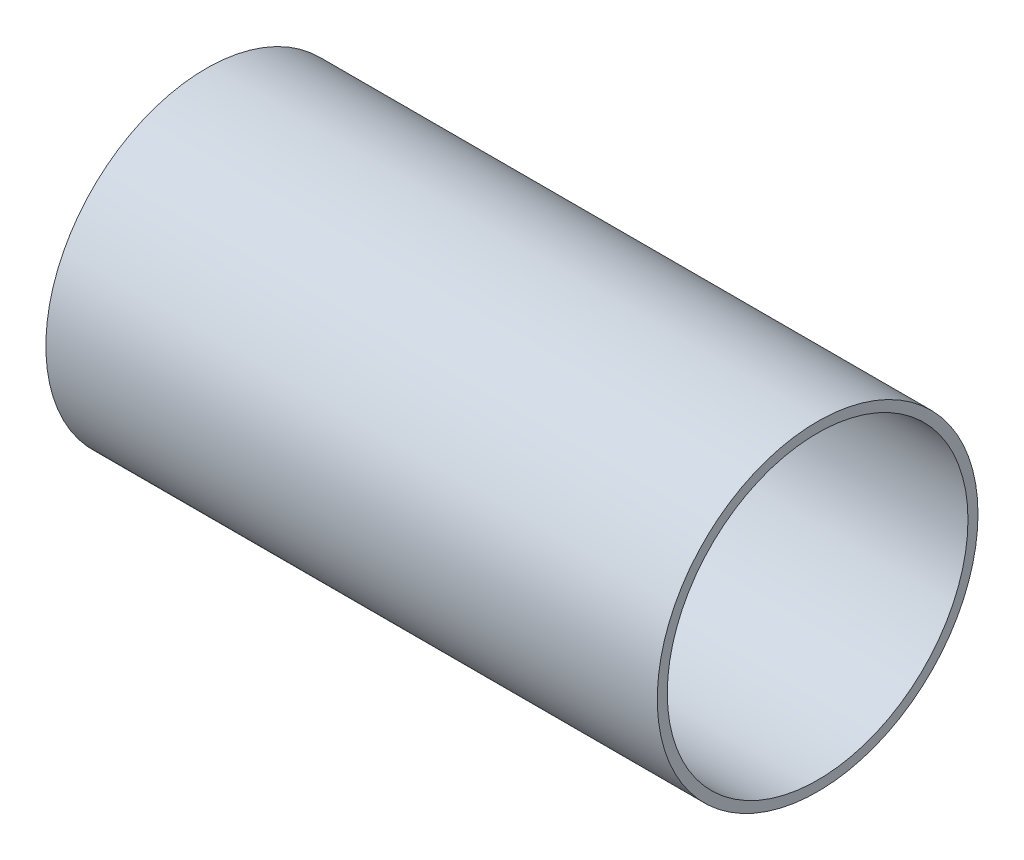
from build123d import *

# Parameters (mm, degrees)
SKETCH1_R           = 101.6
SKETCH1_R_2         = 95.25
BOSS_EXTRUDE1_DEPTH = 387.35


with BuildPart() as part:
    # Sketch1 → Boss-Extrude1 (new body)
    with BuildSketch(Plane(origin=(0, 0, 0), x_dir=(0, 0, -1), z_dir=(1, 0, 0))):
        Circle(SKETCH1_R)
        Circle(SKETCH1_R_2, mode=Mode.SUBTRACT)
    extrude(amount=BOSS_EXTRUDE1_DEPTH)


solid = part.part
